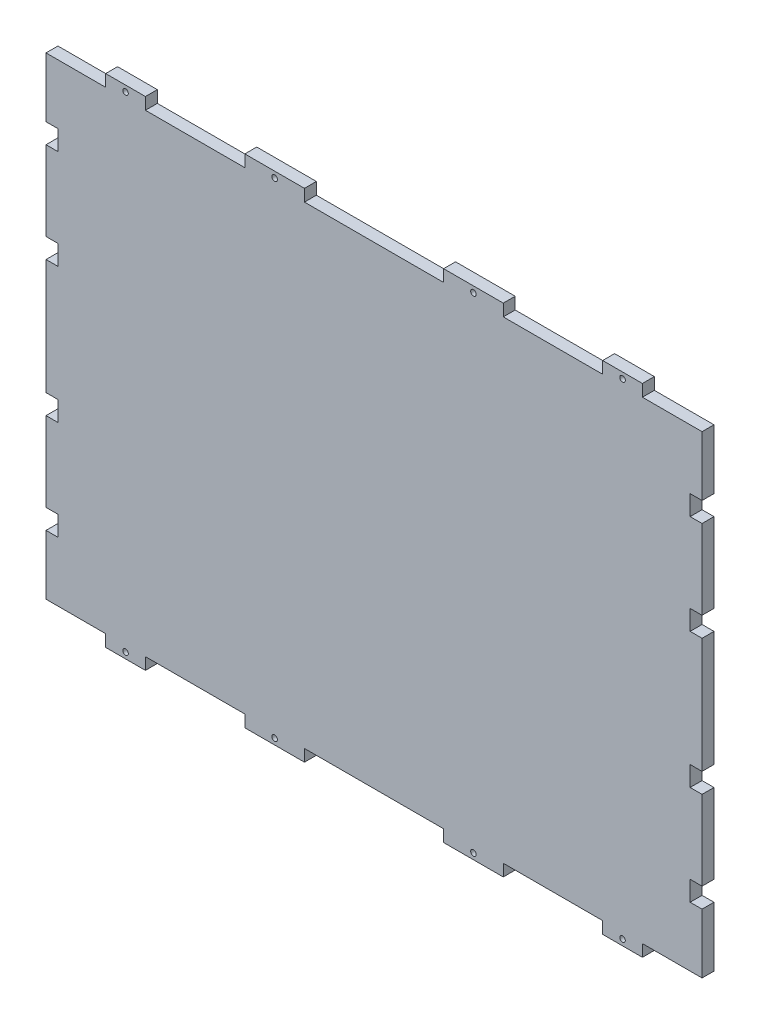
from build123d import *

# Parameters (mm, degrees)
ESQUISSE1_W             = 330
ESQUISSE1_H             = 238
BOSS_EXTRU_1_DEPTH      = 6
ESQUISSE2_W             = 20
ESQUISSE2_H             = 6
ESQUISSE2_W_2           = 30
BOSS_EXTRU_2_DEPTH      = 6
ESQUISSE3_W             = 6
ESQUISSE3_H             = 10
ENL_V_MAT_EXTRU_1_DEPTH = 6
ESQUISSE4_R             = 1.4
ENL_V_MAT_EXTRU_2_DEPTH = 6


with BuildPart() as part:
    # Esquisse1 → Boss.-Extru.1 (new body)
    with BuildSketch(Plane.XY):
        Rectangle(ESQUISSE1_W, ESQUISSE1_H)
    extrude(amount=BOSS_EXTRU_1_DEPTH)

    # Esquisse2 → Boss.-Extru.2 (add)
    with BuildSketch(Plane.XY.offset(6)):
        with Locations((-125, 122)):
            Rectangle(ESQUISSE2_W, ESQUISSE2_H)
        with Locations((-50, 122)):
            Rectangle(ESQUISSE2_W_2, ESQUISSE2_H)
        with Locations((50, 122)):
            Rectangle(ESQUISSE2_W_2, ESQUISSE2_H)
        with Locations((125, 122)):
            Rectangle(ESQUISSE2_W, ESQUISSE2_H)
        with Locations((125, -122)):
            Rectangle(ESQUISSE2_W, ESQUISSE2_H)
        with Locations((50, -122)):
            Rectangle(ESQUISSE2_W_2, ESQUISSE2_H)
        with Locations((-50, -122)):
            Rectangle(ESQUISSE2_W_2, ESQUISSE2_H)
        with Locations((-125, -122)):
            Rectangle(ESQUISSE2_W, ESQUISSE2_H)
    extrude(amount=-BOSS_EXTRU_2_DEPTH)

    # Esquisse3 → Enlèv. mat.-Extru.1 (cut)
    with BuildSketch(Plane.XY.offset(6)):
        with Locations((-162, 84)):
            Rectangle(ESQUISSE3_W, ESQUISSE3_H)
        with Locations((-162, 34)):
            Rectangle(ESQUISSE3_W, ESQUISSE3_H)
        with Locations((-162, -34)):
            Rectangle(ESQUISSE3_W, ESQUISSE3_H)
        with Locations((-162, -84)):
            Rectangle(ESQUISSE3_W, ESQUISSE3_H)
        with Locations((162, -84)):
            Rectangle(ESQUISSE3_W, ESQUISSE3_H)
        with Locations((162, -34)):
            Rectangle(ESQUISSE3_W, ESQUISSE3_H)
        with Locations((162, 34)):
            Rectangle(ESQUISSE3_W, ESQUISSE3_H)
        with Locations((162, 84)):
            Rectangle(ESQUISSE3_W, ESQUISSE3_H)
    extrude(amount=-ENL_V_MAT_EXTRU_1_DEPTH, mode=Mode.SUBTRACT)

    # Esquisse4 → Enlèv. mat.-Extru.2 (cut)
    with BuildSketch(Plane.XY.offset(6)):
        with Locations((-125, 122)):
            Circle(ESQUISSE4_R)
        with Locations((-50, 122)):
            Circle(ESQUISSE4_R)
        with Locations((50, 122)):
            Circle(ESQUISSE4_R)
        with Locations((125, 122)):
            Circle(ESQUISSE4_R)
        with Locations((125, -122)):
            Circle(ESQUISSE4_R)
        with Locations((50, -122)):
            Circle(ESQUISSE4_R)
        with Locations((-50, -122)):
            Circle(ESQUISSE4_R)
        with Locations((-125, -122)):
            Circle(ESQUISSE4_R)
    extrude(amount=-ENL_V_MAT_EXTRU_2_DEPTH, mode=Mode.SUBTRACT)


solid = part.part
